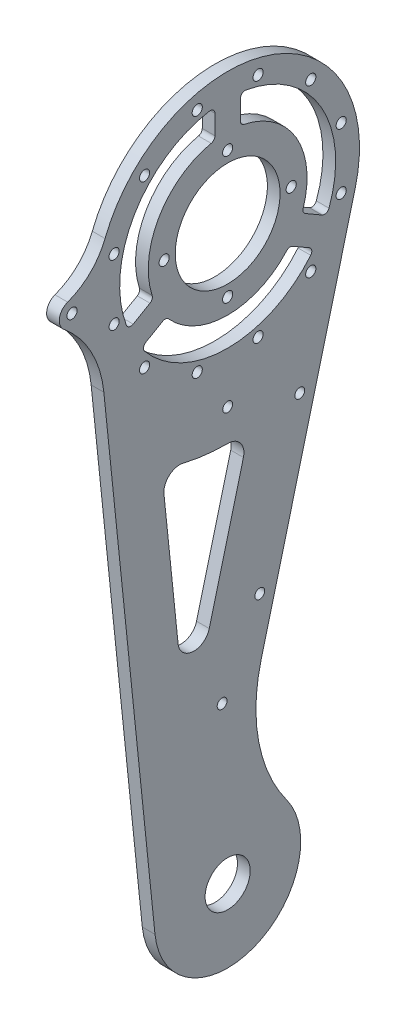
from build123d import *

# Parameters (mm, degrees)
SKETCH_1_R               = 41.5
SKETCH_1_R_2             = 23
EXTRUDE_1_DEPTH          = 4
SKETCH_3_R               = 34
SKETCH_3_R_2             = 7.1
CUT_EXTRUDE_2_DEPTH      = 4
SKETCH_2_R               = 1.6
CUT_EXTRUDE_1_DEPTH      = 4
PATTERN_CIRCULAR_1_COUNT = 12
FILLET_1_R               = 50
SKETCH_4_R               = 1.6
EXTRUDE_2_DEPTH          = 4
FILLET_2_R               = 20
SKETCH_5_R               = 1.55
CUT_EXTRUDE_3_DEPTH      = 44
SKETCH_6_R               = 1.55
CUT_EXTRUDE_4_DEPTH      = 4
SKETCH_7_R               = 16.5
EXTRUDE_3_DEPTH          = 4
SKETCH_8_R               = 1.6
CUT_EXTRUDE_5_DEPTH      = 5
PATTERN_CIRCULAR_3_COUNT = 4
FILLET_3_R               = 1.5
SKETCH_9_R               = 1.55
CUT_EXTRUDE_6_DEPTH      = 10
FILLET_4_R               = 35
CUT_EXTRUDE_7_DEPTH      = 10
FILLET_5_R               = 5


with BuildPart() as part:
    # 草图1 → 凸台-拉伸1 (new body)
    with BuildSketch(Plane(origin=(0, 0, 0), x_dir=(0, 0, -1), z_dir=(1, 0, 0))):
        Circle(SKETCH_1_R)
        with BuildLine():
            Line((1.96511799, -157.084103524), (40.159775356, -10.461474243))
            ThreePointArc((40.159775356, -10.461474243), (-3.1483436, -41.380405177), (-41.280230201, -4.265277778))
            Line((-41.280230201, -4.265277778), (-22.878199871, -182.363888889))
            ThreePointArc((-22.878199871, -182.363888889), (-16.404454744, -163.87877596), (1.96511799, -157.084103524))
        make_face()
        with Locations((0, -180)):
            Circle(SKETCH_1_R_2)
    extrude(amount=EXTRUDE_1_DEPTH)

    # 草图3 → 切除-拉伸2 (cut)
    with BuildSketch(Plane.ZY):
        Circle(SKETCH_3_R)
        with Locations((0, -180)):
            Circle(SKETCH_3_R_2)
    extrude(amount=-CUT_EXTRUDE_2_DEPTH, mode=Mode.SUBTRACT)

    # 草图2 → 切除-拉伸1 (cut)
    with BuildSketch(Plane.ZY):
        with Locations((-9.576304669, 35.739255573)):
            Circle(SKETCH_2_R)
    cut_extrude_1 = extrude(amount=-CUT_EXTRUDE_1_DEPTH, mode=Mode.SUBTRACT)

    # 阵列(圆周)1: 切除-拉伸1 ×12 about axis
    pattern_circular_1_axis = Axis((0, 0, 0), (1, 0, 0))
    for i in range(1, PATTERN_CIRCULAR_1_COUNT):
        add(cut_extrude_1.rotate(pattern_circular_1_axis, i * 360 / PATTERN_CIRCULAR_1_COUNT), mode=Mode.SUBTRACT)

    # 圆角1
    fillet_1_edges = [part.edges().sort_by_distance(p)[0] for p in [
        (2, -157.084103524, -1.96511799),
    ]]
    fillet(fillet_1_edges, radius=FILLET_1_R)

    # 草图4 → 凸台-拉伸2 (add)
    with BuildSketch(Plane(origin=(4, 0, 0), x_dir=(0, 0, -1), z_dir=(1, 0, 0))):
        with BuildLine():
            Line((-49, -4), (-41.306779105, -4))
            ThreePointArc((-41.306779105, -4), (-41.5, 0), (-41.306779105, 4))
            Line((-41.306779105, 4), (-49, 4))
            ThreePointArc((-49, 4), (-53, 0), (-49, -4))
        make_face()
        with Locations((-49, 0)):
            Circle(SKETCH_4_R, mode=Mode.SUBTRACT)
    extrude(amount=-EXTRUDE_2_DEPTH)

    # 圆角2
    fillet_2_edges = [part.edges().sort_by_distance(p)[0] for p in [
        (2, 4, 41.306779105),
    ]]
    fillet(fillet_2_edges, radius=FILLET_2_R)

    # 草图5 → 切除-拉伸3 (cut)
    with BuildSketch(Plane(origin=(4, 0, 0), x_dir=(0, 0, -1), z_dir=(1, 0, 0))):
        with Locations((22.71706237, -57.586327173)):
            Circle(SKETCH_5_R)
        with Locations((10.112876536, -105.971598687)):
            Circle(SKETCH_5_R)
    extrude(amount=-CUT_EXTRUDE_3_DEPTH, mode=Mode.SUBTRACT)

    # 草图6 → 切除-拉伸4 (cut)
    with BuildSketch(Plane(origin=(4, 0, 0), x_dir=(0, 0, -1), z_dir=(1, 0, 0))):
        with Locations((0, -50)):
            Circle(SKETCH_6_R)
    extrude(amount=-CUT_EXTRUDE_4_DEPTH, mode=Mode.SUBTRACT)

    # 草图7 → 凸台-拉伸3 (add)
    with BuildSketch(Plane.ZY):
        with BuildLine():
            ThreePointArc((4, 33.763886032), (0, 34), (-4, 33.763886032))
            Line((-4, 33.763886032), (-4, 24.677925359))
            ThreePointArc((-4, 24.677925359), (-21.650635095, 12.5), (-23.371710273, -8.874861064))
            Line((-23.371710273, -8.874861064), (-31.240383034, -13.417841401))
            ThreePointArc((-31.240383034, -13.417841401), (-29.444863729, -17), (-27.240383034, -20.346044631))
            Line((-27.240383034, -20.346044631), (-19.371710273, -15.803064294))
            ThreePointArc((-19.371710273, -15.803064294), (0, -25), (19.371710273, -15.803064294))
            Line((19.371710273, -15.803064294), (27.240383034, -20.346044631))
            ThreePointArc((27.240383034, -20.346044631), (29.444863729, -17), (31.240383034, -13.417841401))
            Line((31.240383034, -13.417841401), (23.371710273, -8.874861064))
            ThreePointArc((23.371710273, -8.874861064), (21.650635095, 12.5), (4, 24.677925359))
            Line((4, 24.677925359), (4, 33.763886032))
        make_face()
        Circle(SKETCH_7_R, mode=Mode.SUBTRACT)
    extrude(amount=-EXTRUDE_3_DEPTH)

    # 草图8 → 切除-拉伸5 (cut)
    with BuildSketch(Plane(origin=(4, 0, 0), x_dir=(0, 0, -1), z_dir=(1, 0, 0))):
        with Locations((0, 20)):
            Circle(SKETCH_8_R)
    cut_extrude_5 = extrude(amount=-CUT_EXTRUDE_5_DEPTH, mode=Mode.SUBTRACT)

    # 阵列(圆周)3: 切除-拉伸5 ×4 about axis
    pattern_circular_3_axis = Axis((0, 0, 0), (1, 0, 0))
    for i in range(1, PATTERN_CIRCULAR_3_COUNT):
        add(cut_extrude_5.rotate(pattern_circular_3_axis, i * 360 / PATTERN_CIRCULAR_3_COUNT), mode=Mode.SUBTRACT)

    # 圆角3
    fillet_3_edges = [part.edges().sort_by_distance(p)[0] for p in [
        (2, 24.677925359, -4),
        (2, 33.763886032, -4),
        (2, 33.763886032, 4),
        (2, 24.677925359, 4),
        (2, -8.874861064, 23.371710273),
        (2, -13.417841401, 31.240383034),
        (2, -20.346044631, 27.240383034),
        (2, -15.803064294, 19.371710273),
        (2, -15.803064294, -19.371710273),
        (2, -20.346044631, -27.240383034),
        (2, -13.417841401, -31.240383034),
        (2, -8.874861064, -23.371710273),
    ]]
    fillet(fillet_3_edges, radius=FILLET_3_R)

    # 草图9 → 切除-拉伸6 (cut)
    with BuildSketch(Plane(origin=(4, 0, 0), x_dir=(0, 0, -1), z_dir=(1, 0, 0))):
        with Locations((-1.746038475, -130)):
            Circle(SKETCH_9_R)
    extrude(amount=-CUT_EXTRUDE_6_DEPTH, mode=Mode.SUBTRACT)

    # 圆角4
    fillet_4_edges = [part.edges().sort_by_distance(p)[0] for p in [
        (2, -4, 41.306779105),
    ]]
    fillet(fillet_4_edges, radius=FILLET_4_R)

    # 草图10 → 切除-拉伸7 (cut)
    with BuildSketch(Plane(origin=(4, 0, 0), x_dir=(0, 0, -1), z_dir=(1, 0, 0))):
        with BuildLine():
            Line((-20.827059869, -56.269295155), (-12.765282828, -134.292821272))
            Line((-12.765282828, -134.292821272), (6.685040357, -59.626422293))
            ThreePointArc((6.685040357, -59.626422293), (-7.267513648, -59.558234069), (-20.827059869, -56.269295155))
        make_face()
    extrude(amount=-CUT_EXTRUDE_7_DEPTH, mode=Mode.SUBTRACT)

    # 圆角5
    fillet_5_edges = [part.edges().sort_by_distance(p)[0] for p in [
        (2, -56.269295155, 20.827059869),
        (2, -59.626422293, -6.685040357),
        (2, -134.292821272, 12.765282828),
    ]]
    fillet(fillet_5_edges, radius=FILLET_5_R)


solid = part.part
